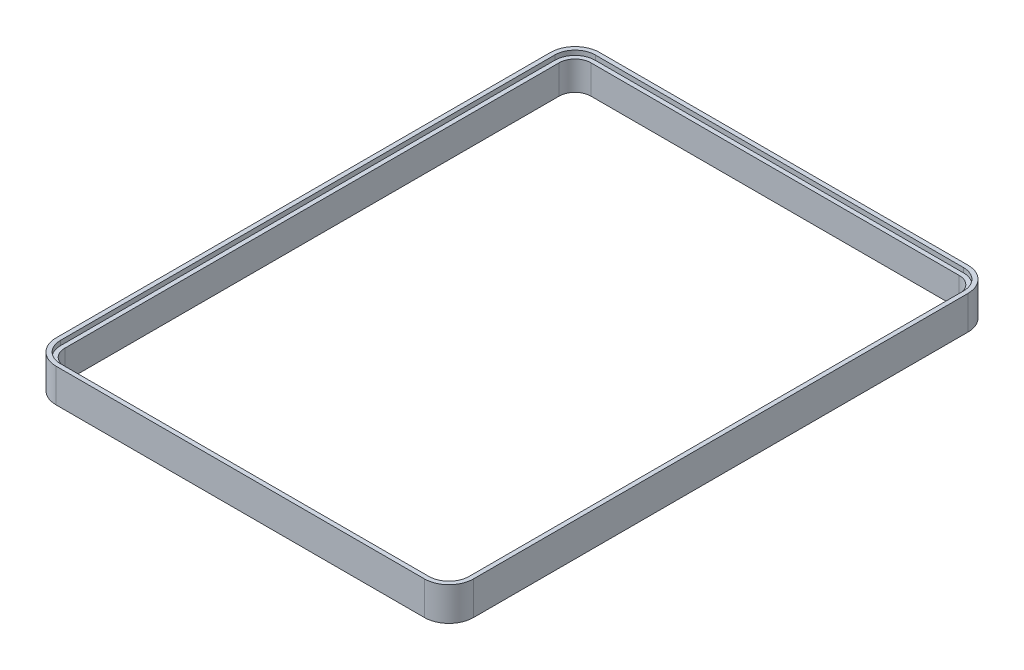
from build123d import *

# Parameters (mm, degrees)
BOSS_EXTRUDE1_DEPTH = 0.8
BOSS_EXTRUDE2_DEPTH = 5


with BuildPart() as part:
    # Sketch1 → Boss-Extrude1 (new body)
    with BuildSketch(Plane(origin=(0, 0, 0), x_dir=(1, 0, 0), z_dir=(0, 1, 0))):
        with BuildLine():
            Line((31.85, 47), (-31.85, 47))
            ThreePointArc((-31.85, 47), (-34.85520382, 45.75520382), (-36.1, 42.75))
            Line((-36.1, 42.75), (-36.1, -42.75))
            ThreePointArc((-36.1, -42.75), (-34.85520382, -45.75520382), (-31.85, -47))
            Line((-31.85, -47), (31.85, -47))
            ThreePointArc((31.85, -47), (34.85520382, -45.75520382), (36.1, -42.75))
            Line((36.1, -42.75), (36.1, 42.75))
            ThreePointArc((36.1, 42.75), (34.85520382, 45.75520382), (31.85, 47))
        make_face()
        with BuildLine():
            Line((35.35, -42.75), (35.35, 42.75))
            ThreePointArc((35.35, 42.75), (34.324873734, 45.224873734), (31.85, 46.25))
            Line((31.85, 46.25), (-31.85, 46.25))
            ThreePointArc((-31.85, 46.25), (-34.324873734, 45.224873734), (-35.35, 42.75))
            Line((-35.35, 42.75), (-35.35, -42.75))
            ThreePointArc((-35.35, -42.75), (-34.324873734, -45.224873734), (-31.85, -46.25))
            Line((-31.85, -46.25), (31.85, -46.25))
            ThreePointArc((31.85, -46.25), (34.324873734, -45.224873734), (35.35, -42.75))
        make_face(mode=Mode.SUBTRACT)
    extrude(amount=-BOSS_EXTRUDE1_DEPTH)

    # Sketch2 → Boss-Extrude2 (add)
    with BuildSketch(Plane.XZ.offset(0.8)):
        with BuildLine():
            Line((36.1, -42.75), (36.1, 42.75))
            ThreePointArc((36.1, 42.75), (34.85520382, 45.75520382), (31.85, 47))
            Line((31.85, 47), (-31.85, 47))
            ThreePointArc((-31.85, 47), (-34.85520382, 45.75520382), (-36.1, 42.75))
            Line((-36.1, 42.75), (-36.1, -42.75))
            ThreePointArc((-36.1, -42.75), (-34.85520382, -45.75520382), (-31.85, -47))
            Line((-31.85, -47), (31.85, -47))
            ThreePointArc((31.85, -47), (34.85520382, -45.75520382), (36.1, -42.75))
        make_face()
        with BuildLine():
            Line((-34.6, 42.75), (-34.6, -42.75))
            ThreePointArc((-34.6, -42.75), (-33.794543648, -44.694543648), (-31.85, -45.5))
            Line((-31.85, -45.5), (31.85, -45.5))
            ThreePointArc((31.85, -45.5), (33.794543648, -44.694543648), (34.6, -42.75))
            Line((34.6, -42.75), (34.6, 42.75))
            ThreePointArc((34.6, 42.75), (33.794543648, 44.694543648), (31.85, 45.5))
            Line((31.85, 45.5), (-31.85, 45.5))
            ThreePointArc((-31.85, 45.5), (-33.794543648, 44.694543648), (-34.6, 42.75))
        make_face(mode=Mode.SUBTRACT)
    extrude(amount=BOSS_EXTRUDE2_DEPTH)


solid = part.part
